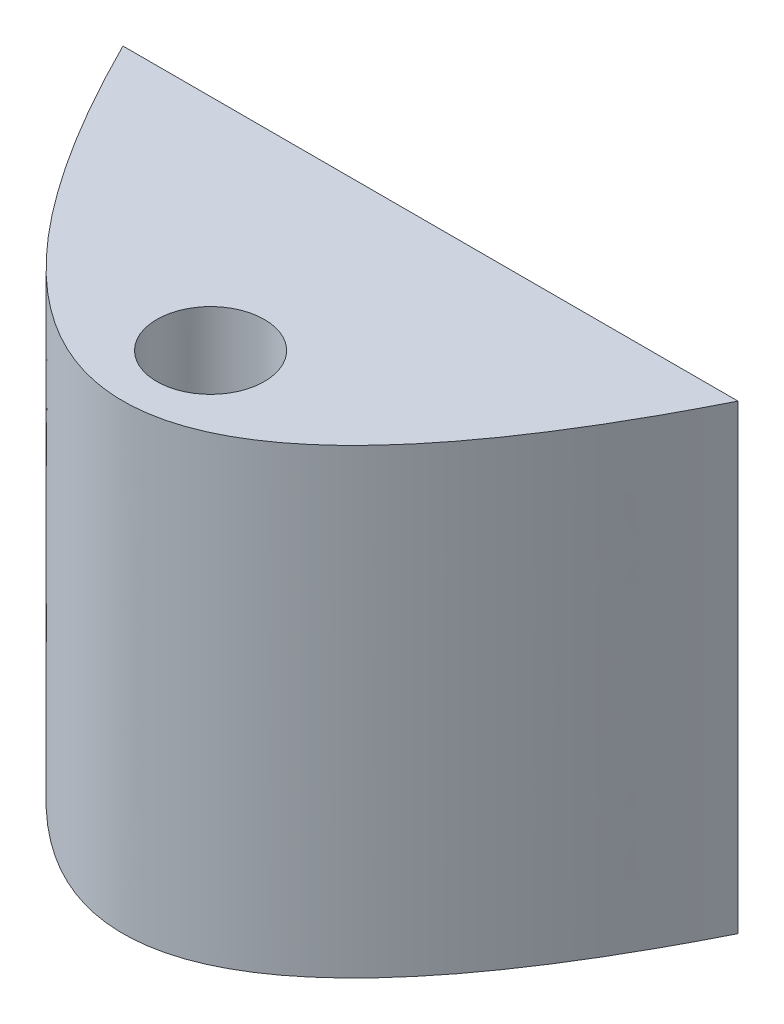
from build123d import *

# Parameters (mm, degrees)
BOSS_EXTRUDE1_DEPTH     = 300
SKETCH3_R               = 15.5
CUT_EXTRUDE1_DEPTH      = 23
CUT_EXTRUDE1_DEPTH_BACK = 23
SKETCH4_R               = 35
CUT_EXTRUDE3_DEPTH      = 300


with BuildPart() as part:
    # Sketch1 → Boss-Extrude1 (new body)
    with BuildSketch(Plane(origin=(0, 0, 0), x_dir=(1, 0, 0), z_dir=(0, 1, 0))):
        with BuildLine():
            Line((-200, 1e-09), (200, 1e-09))
            add(Edge.make_bspline(
                [(-200, 1e-09), (0, -400.000000001), (200, 1e-09)],
                knots=[0.056028396, 0.056028396, 0.056028396, 0.943971604, 0.943971604, 0.943971604], degree=2))
        make_face()
    extrude(amount=BOSS_EXTRUDE1_DEPTH)

    # Sketch3 → Cut-Extrude1 (cut, two sides)
    with BuildSketch(Plane(origin=(0, 150, 0), x_dir=(1, 0, 0), z_dir=(0, 1, 0))) as cut_extrude1_sk:
        with Locations((0, -142.999999999)):
            Circle(SKETCH3_R)
    extrude(amount=CUT_EXTRUDE1_DEPTH, mode=Mode.SUBTRACT)
    extrude(cut_extrude1_sk.sketch, amount=-CUT_EXTRUDE1_DEPTH_BACK, mode=Mode.SUBTRACT)

    # Sketch4 → Cut-Extrude3 (cut)
    with BuildSketch(Plane(origin=(0, 173, 0), x_dir=(1, 0, 0), z_dir=(0, 1, 0))):
        with Locations((0, -142.999999999)):
            Circle(SKETCH4_R)
    cut_extrude3 = extrude(amount=CUT_EXTRUDE3_DEPTH, mode=Mode.SUBTRACT)

    # Mirror1: Cut-Extrude3 across plane
    add(cut_extrude3.mirror(Plane.ZX.offset(150)), mode=Mode.SUBTRACT)


solid = part.part
